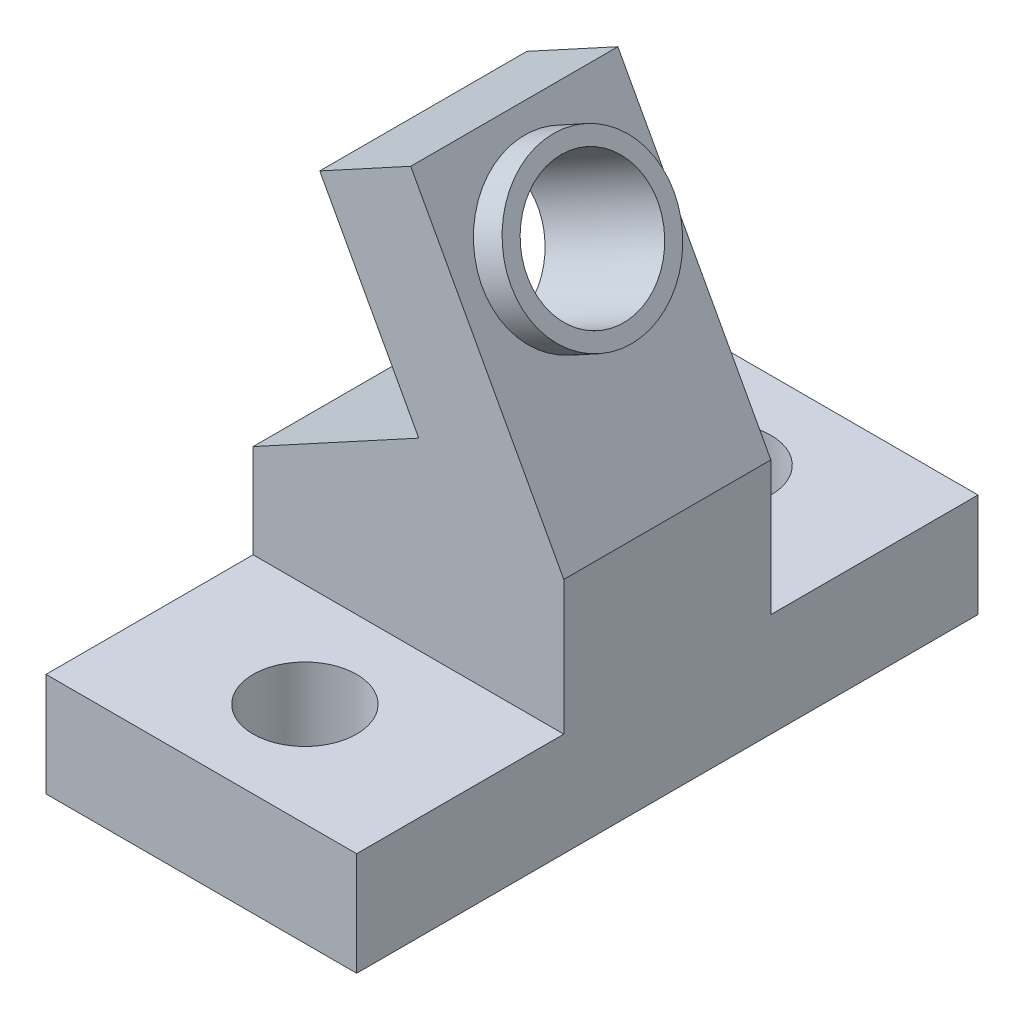
from build123d import *

# Parameters (mm, degrees)
BOSS_EXTRUDE1_DEPTH = 12.7
CUT_EXTRUDE3_REACH  = 25.694
SKETCH2_R           = 4
SKETCH4_R           = 5
SKETCH4_R_2         = 4
BOSS_EXTRUDE2_DEPTH = 2
CUT_EXTRUDE4_REACH  = 14.7
SKETCH5_W           = 6.909894264
SKETCH5_H           = 12.7
SKETCH7_W           = 19.05
SKETCH7_H           = 6.35
BOSS_EXTRUDE3_DEPTH = 12.7
CUT_EXTRUDE5_DEPTH  = 12.7
SKETCH9_R           = 3.175
CUT_EXTRUDE6_DEPTH  = 12.7
SKETCH11_W          = 6.35
SKETCH11_H          = 14.564534892
CUT_EXTRUDE7_DEPTH  = 12.7


with BuildPart() as part:
    # Sketch1 → Boss-Extrude1 (new body)
    with BuildSketch(Plane.XY):
        Polygon((-12.7, 0), (12.7, 0), (12.7, 2.893589299), (-12.7, 49.577371669), align=None)
    extrude(amount=BOSS_EXTRUDE1_DEPTH)

    # Sketch2 → Cut-Extrude3 (cut, up to next)
    with BuildSketch(Plane(origin=(11.013915285, 5.992518901, 0), x_dir=(0.477925491, -0.878400379, 0), z_dir=(0.878400379, 0.477925491, 0)), mode=Mode.PRIVATE) as cut_extrude3_sk1:
        with Locations((-23.045255988, -6.35)):
            Circle(SKETCH2_R)
    cut_extrude3_tool1 = extrude(cut_extrude3_sk1.sketch, amount=-CUT_EXTRUDE3_REACH, mode=Mode.PRIVATE) & part.part
    add(cut_extrude3_tool1.solids().sort_by_distance((0, 26.23548, 6.35))[0], mode=Mode.SUBTRACT)

    # Sketch4 → Boss-Extrude2 (add)
    with BuildSketch(Plane(origin=(11.013915285, 5.992518901, 0), x_dir=(0.477925491, -0.878400379, 0), z_dir=(0.878400379, 0.477925491, 0))):
        with Locations((-23.045255988, -6.35)):
            Circle(SKETCH4_R)
        with Locations((-23.045255988, -6.35)):
            Circle(SKETCH4_R_2, mode=Mode.SUBTRACT)
    extrude(amount=BOSS_EXTRUDE2_DEPTH)

    # Sketch5 → Cut-Extrude4 (cut, up to next)
    with BuildSketch(Plane.XY.offset(12.7), mode=Mode.PRIVATE) as cut_extrude4_sk1:
        with Locations((-9.245052868, 43.227371669)):
            Rectangle(SKETCH5_W, SKETCH5_H)
    cut_extrude4_tool1 = extrude(cut_extrude4_sk1.sketch, amount=-CUT_EXTRUDE4_REACH, mode=Mode.PRIVATE) & part.part
    add(cut_extrude4_tool1.solids().sort_by_distance((-9.245053, 43.227372, 12.7))[0], mode=Mode.SUBTRACT)

    # Sketch7 → Boss-Extrude3 (add)
    with BuildSketch(Plane.XY.offset(12.7)):
        with Locations((-3.175, 3.175)):
            Rectangle(SKETCH7_W, SKETCH7_H)
    boss_extrude3 = extrude(amount=BOSS_EXTRUDE3_DEPTH)

    # Sketch8 → Cut-Extrude5 (cut)
    with BuildSketch(Plane.XY.offset(12.7)):
        Polygon((-8.612669272, 28.778496019), (-2.543015535, 17.622811212), (-12.7, 12.096536512), (-12.7, 26.554635929), align=None)
    extrude(amount=-CUT_EXTRUDE5_DEPTH, mode=Mode.SUBTRACT)

    # Sketch9 → Cut-Extrude6 (cut)
    with BuildSketch(Plane(origin=(0, 6.35, 0), x_dir=(1, 0, 0), z_dir=(0, 1, 0))):
        with Locations((-3.175, -19.05)):
            Circle(SKETCH9_R)
    cut_extrude6 = extrude(amount=-CUT_EXTRUDE6_DEPTH, mode=Mode.SUBTRACT)

    # Mirror1: Boss-Extrude3, Cut-Extrude6 across plane
    add(boss_extrude3.mirror(Plane.XY.offset(6.35)))
    add(cut_extrude6.mirror(Plane.XY.offset(6.35)), mode=Mode.SUBTRACT)

    # Sketch11 → Cut-Extrude7 (cut)
    with BuildSketch(Plane.XY.offset(12.7)):
        Polygon((-12.7, 26.554635929), (-3.034826868, 31.813322888), (-5.790105736, 36.877371669), (-12.7, 36.877371669), align=None)
        with Locations((9.525, 7.282267446)):
            Rectangle(SKETCH11_W, SKETCH11_H)
    extrude(amount=-CUT_EXTRUDE7_DEPTH, mode=Mode.SUBTRACT)


solid = part.part
